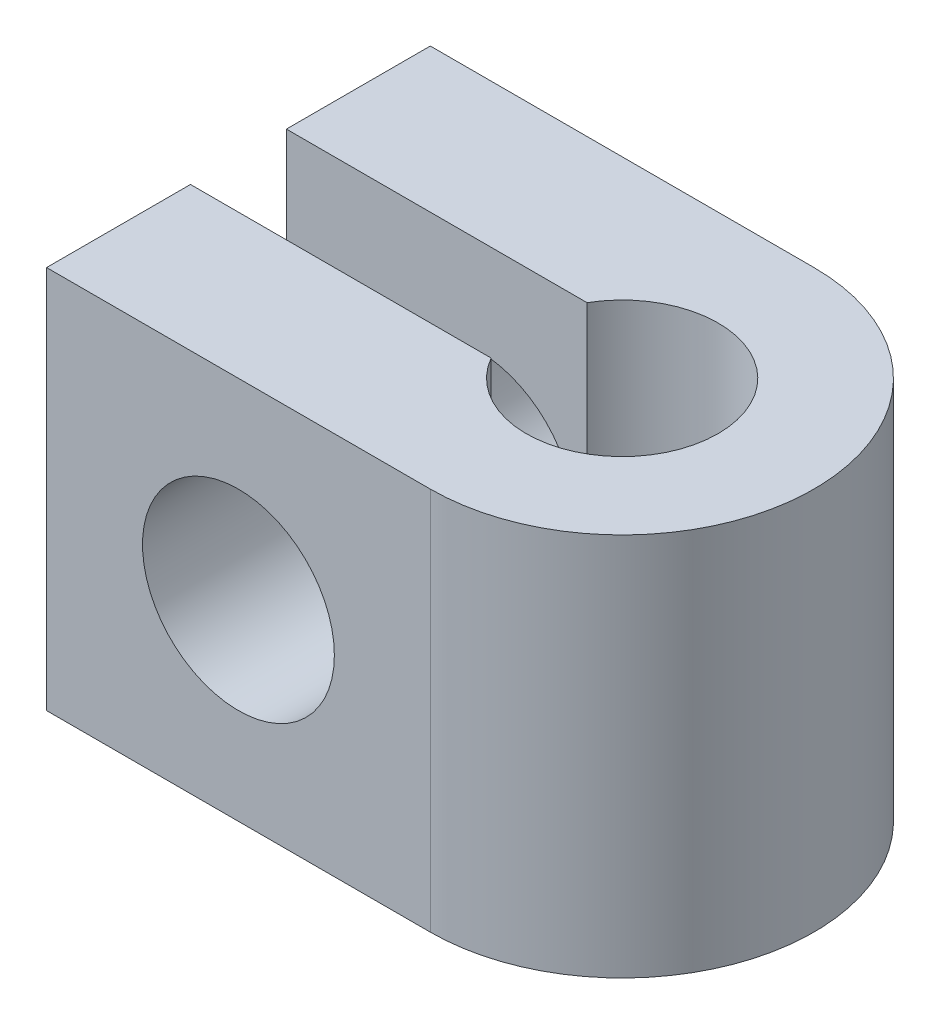
from build123d import *

# Parameters (mm, degrees)
BOSS_EXTRUDE1_DEPTH = 12.7
SKETCH2_R           = 3.175
CUT_EXTRUDE1_DEPTH  = 13.7


with BuildPart() as part:
    # Sketch1 → Boss-Extrude1 (new body)
    with BuildSketch(Plane(origin=(0, 0, 0), x_dir=(1, 0, 0), z_dir=(0, 1, 0))):
        with BuildLine():
            Line((0, 0), (-12.7, 0))
            Line((-12.7, 0), (-12.7, -4.7625))
            Line((-12.7, -4.7625), (-2.749630657, -4.7625))
            ThreePointArc((-2.749630657, -4.7625), (3.175, -6.35), (-2.749630657, -7.9375))
            Line((-2.749630657, -7.9375), (-12.7, -7.9375))
            Line((-12.7, -7.9375), (-12.7, -12.7))
            Line((-12.7, -12.7), (0, -12.7))
            ThreePointArc((0, -12.7), (6.35, -6.35), (0, 0))
        make_face()
    extrude(amount=BOSS_EXTRUDE1_DEPTH)

    # Sketch2 → Cut-Extrude1 (cut, through all)
    with BuildSketch(Plane.XY.offset(12.7)):
        with Locations((-6.35, 6.35)):
            Circle(SKETCH2_R)
    extrude(amount=-CUT_EXTRUDE1_DEPTH, mode=Mode.SUBTRACT)


solid = part.part
